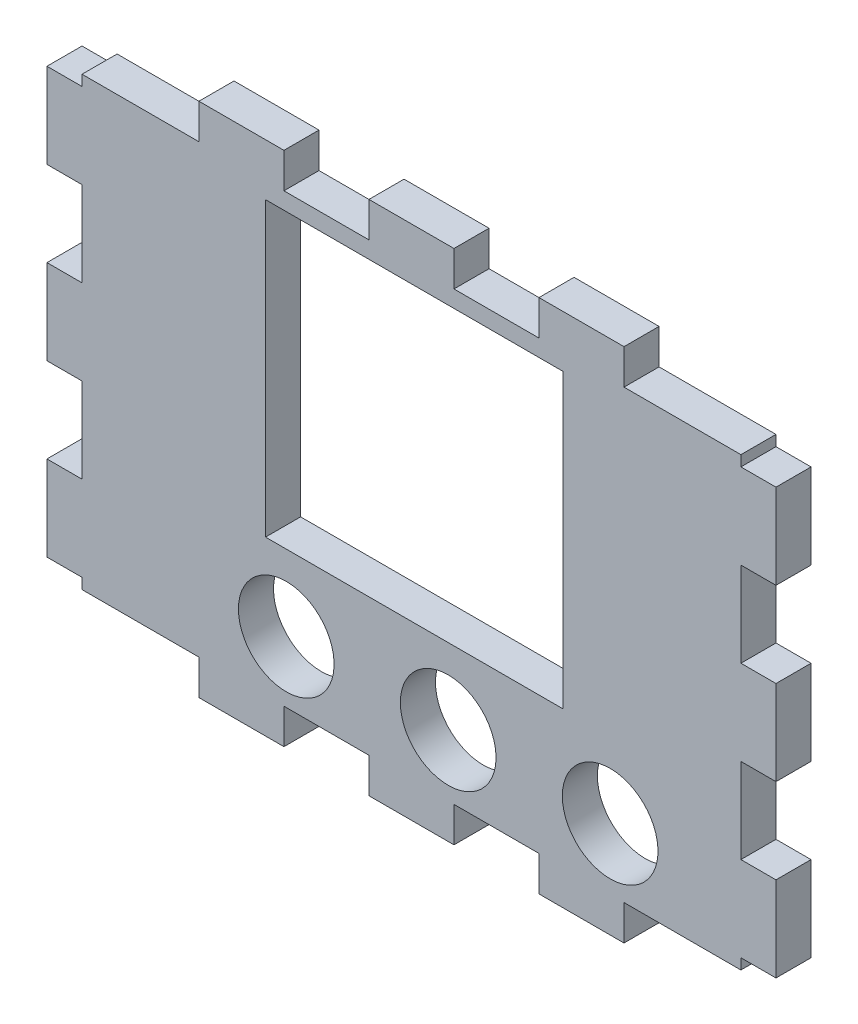
from build123d import *

# Parameters (mm, degrees)
ESQUISSE1_W                    = 62
ESQUISSE1_H                    = 42
BOSS_EXTRU_1_DEPTH             = 3.3
ESQUISSE2_W                    = 8
ESQUISSE2_H                    = 3.3
BOSS_EXTRU_2_DEPTH             = 3.3
R_P_TITION_LIN_AIRE1_COUNT     = 2
R_P_TITION_LIN_AIRE1_PITCH     = 16
R_P_TITION_LIN_AIRE1_COL_COUNT = 2
R_P_TITION_LIN_AIRE1_COL_PITCH = 16
SYM_TRIE1_COPY_1_SKETCH_W      = 8
SYM_TRIE1_COPY_1_SKETCH_H      = 3.3
SYM_TRIE1_COPY_1_DEPTH         = 3.3
SYM_TRIE1_COPY_2_SKETCH_W      = 8
SYM_TRIE1_COPY_2_SKETCH_H      = 3.3
SYM_TRIE1_COPY_2_DEPTH         = 3.3
ESQUISSE3_W                    = 3.3
ESQUISSE3_H                    = 8
BOSS_EXTRU_3_DEPTH             = 3.3
R_P_TITION_LIN_AIRE2_COUNT     = 2
R_P_TITION_LIN_AIRE2_PITCH     = 16
R_P_TITION_LIN_AIRE2_COL_COUNT = 2
R_P_TITION_LIN_AIRE2_COL_PITCH = 16
SYM_TRIE2_COPY_1_SKETCH_W      = 3.3
SYM_TRIE2_COPY_1_SKETCH_H      = 8
SYM_TRIE2_COPY_1_DEPTH         = 3.3
SYM_TRIE2_COPY_2_SKETCH_W      = 3.3
SYM_TRIE2_COPY_2_SKETCH_H      = 8
SYM_TRIE2_COPY_2_DEPTH         = 3.3
ESQUISSE4_R                    = 4.5
ESQUISSE4_W                    = 28
ESQUISSE4_H                    = 27.5
ENL_V_MAT_EXTRU_2_DEPTH        = 1
ENL_V_MAT_EXTRU_2_DEPTH_BACK   = 4.3


with BuildPart() as part:
    # Esquisse1 → Boss.-Extru.1 (new body)
    with BuildSketch(Plane.XY):
        Rectangle(ESQUISSE1_W, ESQUISSE1_H)
    extrude(amount=BOSS_EXTRU_1_DEPTH)

    # Esquisse2 → Boss.-Extru.2 (add)
    with BuildSketch(Plane.XY.offset(3.3)):
        with Locations((0, 22.65)):
            Rectangle(ESQUISSE2_W, ESQUISSE2_H)
    boss_extru_2 = extrude(amount=-BOSS_EXTRU_2_DEPTH)

    # Répétition linéaire1: Boss.-Extru.2 ×2
    with Locations(*[(-i * R_P_TITION_LIN_AIRE1_PITCH, 0, 0) for i in range(1, R_P_TITION_LIN_AIRE1_COUNT)]):
        add(boss_extru_2)

    # Répétition linéaire1 col: Boss.-Extru.2 ×2
    with Locations(*[(i * R_P_TITION_LIN_AIRE1_COL_PITCH, 0, 0) for i in range(1, R_P_TITION_LIN_AIRE1_COL_COUNT)]):
        add(boss_extru_2)

    # Symétrie1: Boss.-Extru.2 across plane
    add(boss_extru_2.mirror(Plane.ZX))

    # Symétrie1 copy 1 sketch → Symétrie1 copy 1 (add)
    with BuildSketch(Plane(origin=(-16, 0, 3.3), x_dir=(1, 0, 0), z_dir=(0, 0, 1))):
        with Locations((0, -22.65)):
            Rectangle(SYM_TRIE1_COPY_1_SKETCH_W, SYM_TRIE1_COPY_1_SKETCH_H)
    extrude(amount=-SYM_TRIE1_COPY_1_DEPTH)

    # Symétrie1 copy 2 sketch → Symétrie1 copy 2 (add)
    with BuildSketch(Plane(origin=(16, 0, 3.3), x_dir=(1, 0, 0), z_dir=(0, 0, 1))):
        with Locations((0, -22.65)):
            Rectangle(SYM_TRIE1_COPY_2_SKETCH_W, SYM_TRIE1_COPY_2_SKETCH_H)
    extrude(amount=-SYM_TRIE1_COPY_2_DEPTH)

    # Esquisse3 → Boss.-Extru.3 (add)
    with BuildSketch(Plane.XY.offset(3.3)):
        with Locations((-32.65, 0)):
            Rectangle(ESQUISSE3_W, ESQUISSE3_H)
    boss_extru_3 = extrude(amount=-BOSS_EXTRU_3_DEPTH)

    # Répétition linéaire2: Boss.-Extru.3 ×2
    with Locations(*[(0, i * R_P_TITION_LIN_AIRE2_PITCH, 0) for i in range(1, R_P_TITION_LIN_AIRE2_COUNT)]):
        add(boss_extru_3)

    # Répétition linéaire2 col: Boss.-Extru.3 ×2
    with Locations(*[(0, -i * R_P_TITION_LIN_AIRE2_COL_PITCH, 0) for i in range(1, R_P_TITION_LIN_AIRE2_COL_COUNT)]):
        add(boss_extru_3)

    # Symétrie2: Boss.-Extru.3 across plane
    add(boss_extru_3.mirror(Plane(origin=(0, 0, 0), x_dir=(0, 0, 1), z_dir=(1, 0, 0))))

    # Symétrie2 copy 1 sketch → Symétrie2 copy 1 (add)
    with BuildSketch(Plane(origin=(0, 16, 3.3), x_dir=(-1, 0, 0), z_dir=(0, 0, 1))):
        with Locations((-32.65, 0)):
            Rectangle(SYM_TRIE2_COPY_1_SKETCH_W, SYM_TRIE2_COPY_1_SKETCH_H)
    extrude(amount=-SYM_TRIE2_COPY_1_DEPTH)

    # Symétrie2 copy 2 sketch → Symétrie2 copy 2 (add)
    with BuildSketch(Plane(origin=(0, -16, 3.3), x_dir=(-1, 0, 0), z_dir=(0, 0, 1))):
        with Locations((-32.65, 0)):
            Rectangle(SYM_TRIE2_COPY_2_SKETCH_W, SYM_TRIE2_COPY_2_SKETCH_H)
    extrude(amount=-SYM_TRIE2_COPY_2_DEPTH)

    # Esquisse4 → Enlèv. mat.-Extru.2 (cut, two sides)
    with BuildSketch(Plane(origin=(0, 0, 0), x_dir=(-1, 0, 0), z_dir=(0, 0, -1))) as enl_v_mat_extru_2_sk:
        with Locations((-18.697468538, -15.21869301)):
            Circle(ESQUISSE4_R)
        with Locations((-3.457468538, -15.21869301)):
            Circle(ESQUISSE4_R)
        with Locations((11.782531462, -15.21869301)):
            Circle(ESQUISSE4_R)
        with Locations((-0.267723221, 5.663046026)):
            Rectangle(ESQUISSE4_W, ESQUISSE4_H)
    extrude(amount=ENL_V_MAT_EXTRU_2_DEPTH, mode=Mode.SUBTRACT)
    extrude(enl_v_mat_extru_2_sk.sketch, amount=-ENL_V_MAT_EXTRU_2_DEPTH_BACK, mode=Mode.SUBTRACT)


solid = part.part
